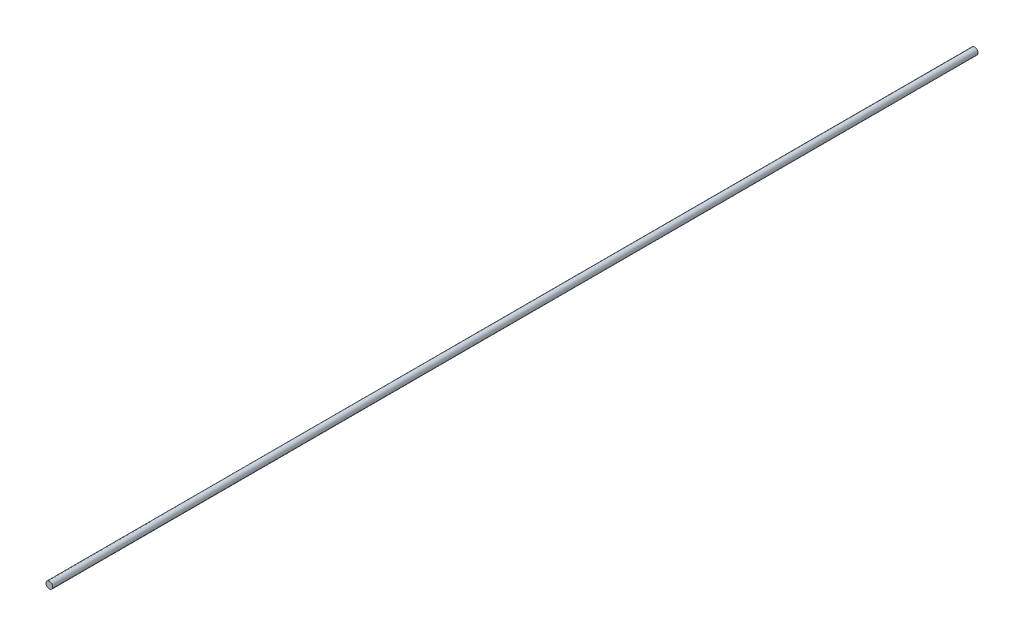
from build123d import *

# Parameters (mm, degrees)
SKETCH1_R           = 2.413
BOSS_EXTRUDE1_DEPTH = 660.4


with BuildPart() as part:
    # Sketch1 → Boss-Extrude1 (new body)
    with BuildSketch(Plane.XY):
        Circle(SKETCH1_R)
    extrude(amount=BOSS_EXTRUDE1_DEPTH)


solid = part.part
